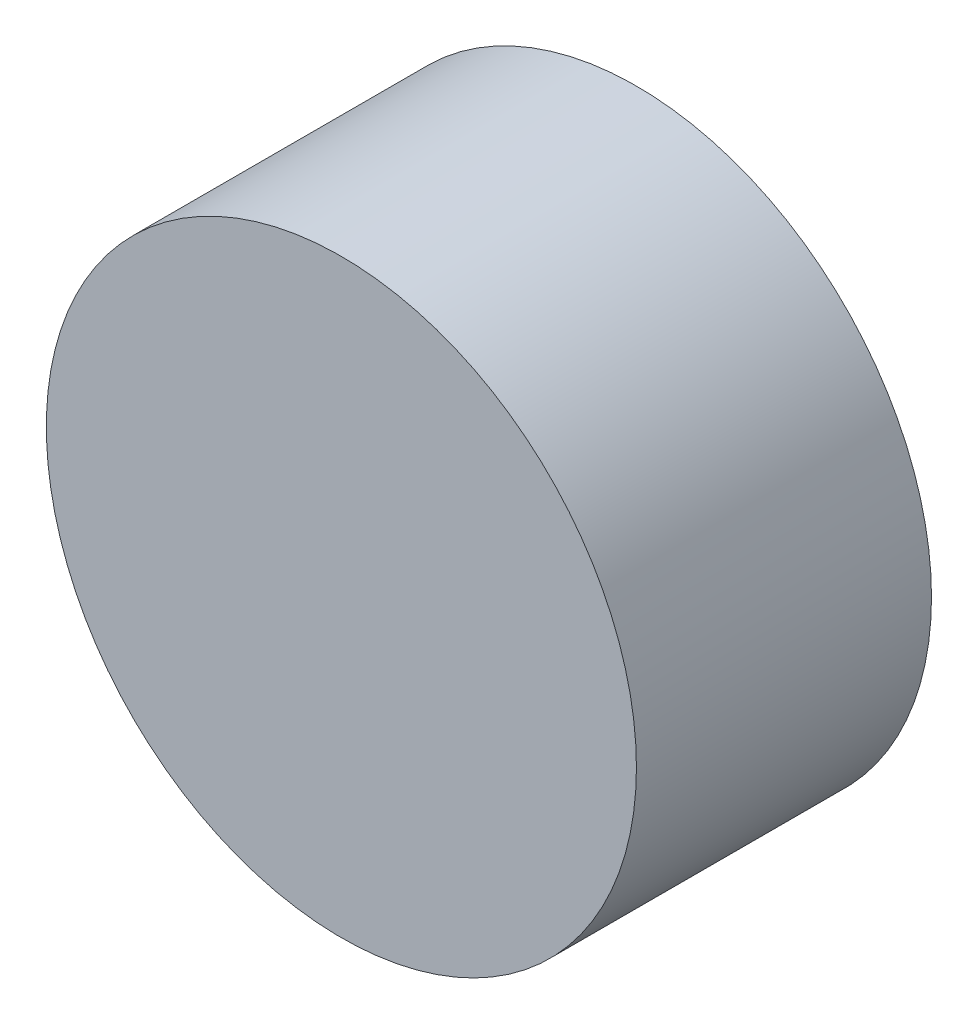
from build123d import *

# Parameters (mm, degrees)
SKETCH1_R           = 100
BOSS_EXTRUDE1_DEPTH = 100


with BuildPart() as part:
    # Sketch1 → Boss-Extrude1 (new body)
    with BuildSketch(Plane.XY):
        Circle(SKETCH1_R)
    extrude(amount=BOSS_EXTRUDE1_DEPTH)


solid = part.part
